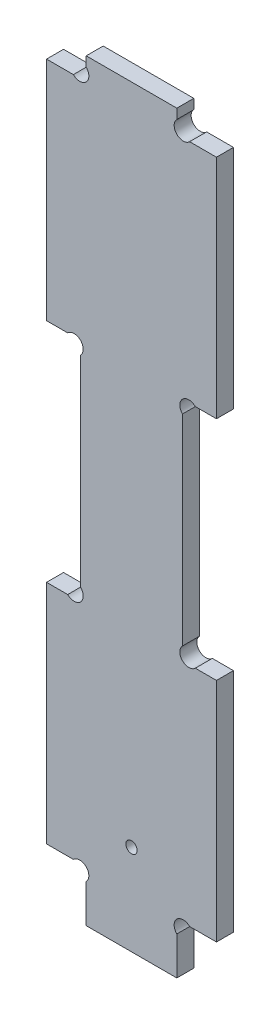
from build123d import *

# Parameters (mm, degrees)
EXTRUSION1_DEPTH        = 3
ESQUISSE2_R             = 1
ENL_V_MAT_EXTRU_1_DEPTH = 4


with BuildPart() as part:
    # Esquisse1 → Extrusion1 (new body)
    with BuildSketch(Plane.XY):
        with BuildLine():
            Line((25.2627417, 9), (30, 9))
            Line((30, 9), (30, 49))
            Line((30, 49), (26.2627417, 49))
            ThreePointArc((26.2627417, 49), (24, 49), (24, 51.2627417))
            Line((24, 51.2627417), (24, 86.7372583))
            ThreePointArc((24, 86.7372583), (24, 89), (26.2627417, 89))
            Line((26.2627417, 89), (30, 89))
            Line((30, 89), (30, 129))
            Line((30, 129), (25.2627417, 129))
            ThreePointArc((25.2627417, 129), (23, 129), (23, 131.2627417))
            Line((23, 131.2627417), (23, 133))
            Line((23, 133), (7, 133))
            Line((7, 133), (7, 131.2627417))
            ThreePointArc((7, 131.2627417), (7, 129), (4.7372583, 129))
            Line((4.7372583, 129), (0, 129))
            Line((0, 129), (0, 89))
            Line((0, 89), (3.7372583, 89))
            ThreePointArc((3.7372583, 89), (6, 89), (6, 86.7372583))
            Line((6, 86.7372583), (6, 51.2627417))
            ThreePointArc((6, 51.2627417), (6, 49), (3.7372583, 49))
            Line((3.7372583, 49), (0, 49))
            Line((0, 49), (0, 9))
            Line((0, 9), (4.7372583, 9))
            ThreePointArc((4.7372583, 9), (7, 9), (7, 6.7372583))
            Line((7, 6.7372583), (7, 0))
            Line((7, 0), (23, 0))
            Line((23, 0), (23, 6.7372583))
            ThreePointArc((23, 6.7372583), (23, 9), (25.2627417, 9))
        make_face()
    extrude(amount=EXTRUSION1_DEPTH)

    # Esquisse2 → Enlèv. mat.-Extru.1 (cut, through all)
    with BuildSketch(Plane.XY.offset(3)):
        with Locations((15, 16)):
            Circle(ESQUISSE2_R)
    extrude(amount=-ENL_V_MAT_EXTRU_1_DEPTH, mode=Mode.SUBTRACT)


solid = part.part
